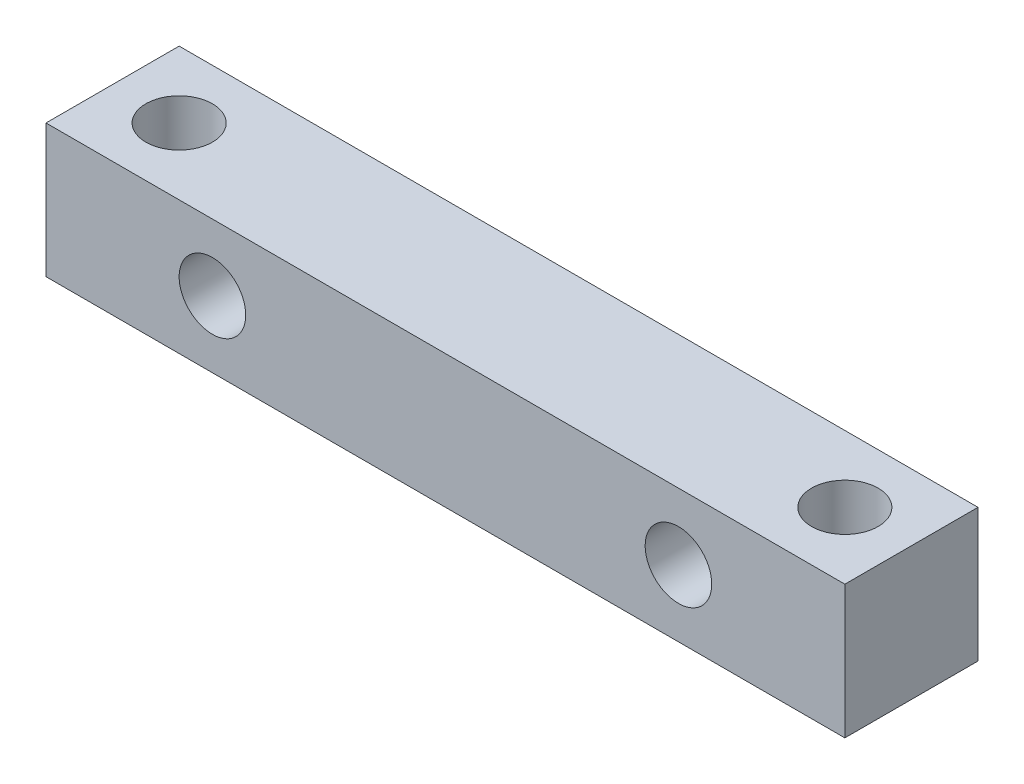
from build123d import *

# Parameters (mm, degrees)
ESQUISSE1_W             = 36
ESQUISSE1_H             = 6
BOSS_EXTRU_1_DEPTH      = 6
ESQUISSE2_R             = 1.5
ENL_V_MAT_EXTRU_1_DEPTH = 60
ESQUISSE3_R             = 1.5
ENL_V_MAT_EXTRU_2_DEPTH = 6


with BuildPart() as part:
    # Esquisse1 → Boss.-Extru.1 (new body)
    with BuildSketch(Plane(origin=(0, 0, 0), x_dir=(1, 0, 0), z_dir=(0, 1, 0))):
        Rectangle(ESQUISSE1_W, ESQUISSE1_H)
    extrude(amount=BOSS_EXTRU_1_DEPTH)

    # Esquisse2 → Enlèv. mat.-Extru.1 (cut)
    with BuildSketch(Plane(origin=(0, 6, 0), x_dir=(1, 0, 0), z_dir=(0, 1, 0))):
        with Locations((-15, 0)):
            Circle(ESQUISSE2_R)
    enl_v_mat_extru_1 = extrude(amount=-ENL_V_MAT_EXTRU_1_DEPTH, mode=Mode.SUBTRACT)

    # Symétrie1: Enlèv. mat.-Extru.1 across plane
    add(enl_v_mat_extru_1.mirror(Plane(origin=(0, 0, 0), x_dir=(0, 0, 1), z_dir=(1, 0, 0))), mode=Mode.SUBTRACT)

    # Esquisse3 → Enlèv. mat.-Extru.2 (cut)
    with BuildSketch(Plane.XY.offset(3)):
        with Locations((-10.5, 3)):
            Circle(ESQUISSE3_R)
    enl_v_mat_extru_2 = extrude(amount=-ENL_V_MAT_EXTRU_2_DEPTH, mode=Mode.SUBTRACT)

    # Symétrie2: Enlèv. mat.-Extru.2 across plane
    add(enl_v_mat_extru_2.mirror(Plane(origin=(0, 0, 0), x_dir=(0, 0, 1), z_dir=(1, 0, 0))), mode=Mode.SUBTRACT)


solid = part.part
